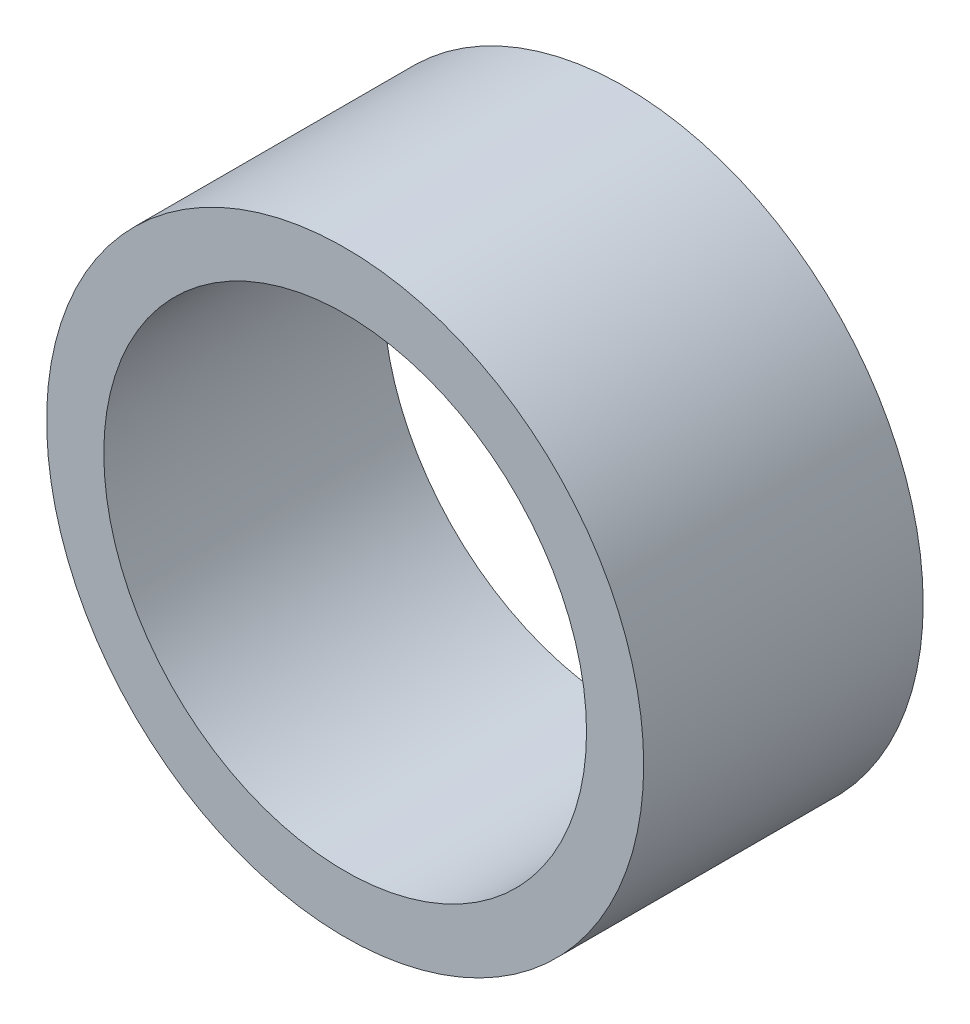
from build123d import *

# Parameters (mm, degrees)
ESQUISSE1_R        = 23.5
ESQUISSE1_R_2      = 19
BOSS_EXTRU_1_DEPTH = 22


with BuildPart() as part:
    # Esquisse1 → Boss.-Extru.1 (new body)
    with BuildSketch(Plane.XY):
        Circle(ESQUISSE1_R)
        Circle(ESQUISSE1_R_2, mode=Mode.SUBTRACT)
    extrude(amount=BOSS_EXTRU_1_DEPTH)


solid = part.part
